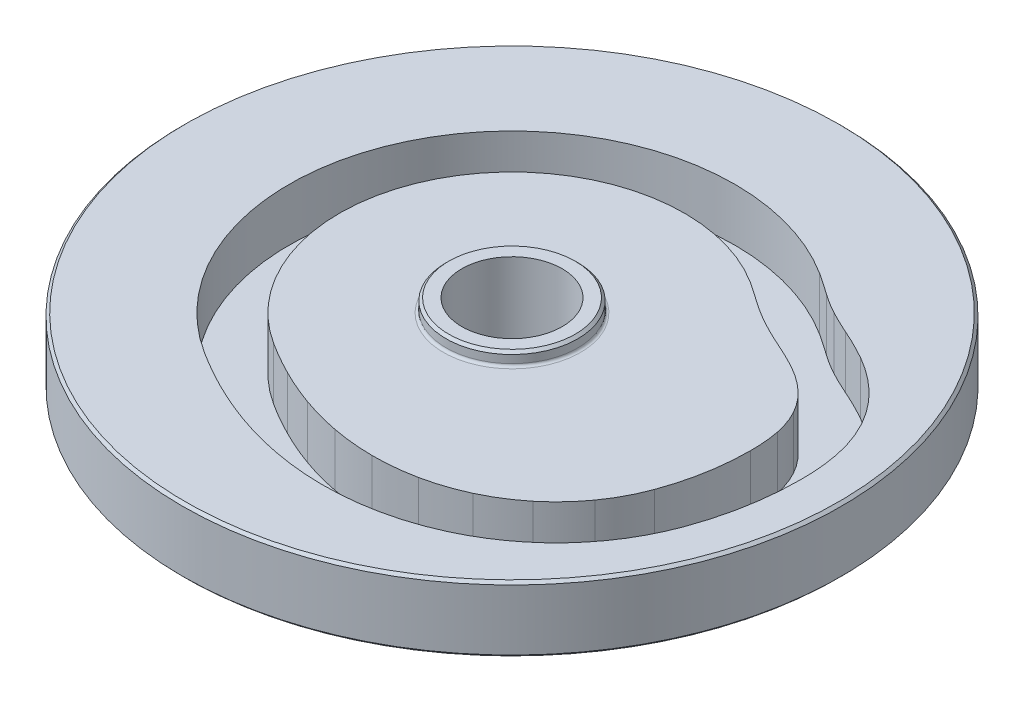
from build123d import *

# Parameters (mm, degrees)
CUT_EXTRUDE_THIN1_DEPTH      = 15
CUT_EXTRUDE_THIN1_DEPTH_BACK = 20


with BuildPart() as part:
    # Sketch1 → Base-Revolve (revolve)
    with BuildSketch(Plane.XY):
        with BuildLine():
            Line((19.05, 5), (24, 5))
            Line((24, 5), (25, 4))
            Line((25, 4), (25, 1))
            ThreePointArc((25, 1), (25.292893219, 0.292893219), (26, 0))
            Line((26, 0), (124, 0))
            Line((124, 0), (125, -1))
            Line((125, -1), (125, -24))
            Line((125, -24), (124, -25))
            Line((124, -25), (26, -25))
            ThreePointArc((26, -25), (25.292893219, -25.292893219), (25, -26))
            Line((25, -26), (25, -29))
            Line((25, -29), (24, -30))
            Line((24, -30), (19.05, -30))
            Line((19.05, -30), (19.05, 5))
        make_face()
    revolve(axis=Axis((0, -30350, 0), (0, 1, 0)))

    # Sketch2 → Cut-Extrude-Thin1 (cut, two sides)
    with BuildSketch(Plane(origin=(0, 0, 0), x_dir=(1, 0, 0), z_dir=(0, 1, 0))) as cut_extrude_thin1_sk:
        with BuildLine():
            ThreePointArc((109.524986247, -0.054887133), (109.229921991, 7.423375501), (108.184717895, 14.834112532))
            ThreePointArc((108.184717895, 14.834112532), (106.043659804, 22.548927161), (102.756924095, 29.84960267))
            ThreePointArc((102.756924095, 29.84960267), (98.332860497, 36.567183371), (92.916011248, 42.513272287))
            ThreePointArc((92.916011248, 42.513272287), (87.141221214, 47.295885443), (80.843977188, 51.366058191))
            ThreePointArc((80.843977188, 51.366058191), (75.279655517, 54.316272842), (69.579158541, 56.993916655))
            ThreePointArc((69.579158541, 56.993916655), (65.230785476, 58.999236045), (60.953055197, 61.151137028))
            ThreePointArc((60.953055197, 61.151137028), (57.290135984, 63.276226982), (53.749285638, 65.599019115))
            ThreePointArc((53.749285638, 65.599019115), (49.601954473, 68.481518372), (45.406369026, 71.293318599))
            ThreePointArc((45.406369026, 71.293318599), (-71.312570217, 45.376127579), (-45.345877971, -71.331809006))
            ThreePointArc((-45.345877971, -71.331809006), (-38.593898018, -75.405527827), (-31.649923168, -79.142589722))
            ThreePointArc((-31.649923168, -79.142589722), (-24.034421899, -82.711545409), (-16.211151125, -85.798572893))
            ThreePointArc((-16.211151125, -85.798572893), (-7.620932162, -88.510877367), (1.153325471, -90.550696085))
            ThreePointArc((1.153325471, -90.550696085), (10.620649637, -91.921398106), (20.173660561, -92.420430343))
            ThreePointArc((20.173660561, -92.420430343), (30.195991067, -91.960061817), (40.115734041, -90.457481608))
            ThreePointArc((40.115734041, -90.457481608), (50.164053761, -87.778443627), (59.835395829, -83.955994636))
            ThreePointArc((59.835395829, -83.955994636), (69.217053614, -78.865285844), (77.888616734, -72.641556104))
            ThreePointArc((77.888616734, -72.641556104), (85.826699629, -65.22323814), (92.717665183, -56.823286045))
            ThreePointArc((92.717665183, -56.823286045), (98.476591418, -47.488521124), (102.919592608, -37.460420212))
            ThreePointArc((102.919592608, -37.460420212), (107.856238797, -19.046190631), (109.524986247, -0.054887133))
        make_face()
        with BuildLine():
            ThreePointArc((90.474982456, 0.056342792), (90.262741838, 5.647173284), (89.486847533, 11.187969228))
            ThreePointArc((89.486847533, 11.187969228), (88.12991005, 16.068178084), (86.054133631, 20.688661832))
            ThreePointArc((86.054133631, 20.688661832), (83.284958022, 24.885433828), (79.899946609, 28.603353472))
            ThreePointArc((79.899946609, 28.603353472), (75.875178075, 31.93428485), (71.488414915, 34.771567807))
            ThreePointArc((71.488414915, 34.771567807), (66.751022738, 37.282035549), (61.898062734, 39.56109503))
            ThreePointArc((61.898062734, 39.56109503), (56.897401317, 41.868517981), (51.979131099, 44.346709525))
            ThreePointArc((51.979131099, 44.346709525), (47.310945971, 47.049113929), (42.801511531, 50.008834013))
            ThreePointArc((42.801511531, 50.008834013), (38.952515201, 52.685804726), (35.059073926, 55.297712072))
            ThreePointArc((35.059073926, 55.297712072), (-55.279422123, 35.087905534), (-35.1167276, -55.261117141))
            ThreePointArc((-35.1167276, -55.261117141), (-29.160317457, -58.855298852), (-23.034341253, -62.152173057))
            ThreePointArc((-23.034341253, -62.152173057), (-16.494338073, -65.217270915), (-9.775872963, -67.868439157))
            ThreePointArc((-9.775872963, -67.868439157), (-2.592647115, -70.136469906), (4.744453336, -71.842240708))
            ThreePointArc((4.744453336, -71.842240708), (12.484550044, -72.962801762), (20.294689574, -73.370814789))
            ThreePointArc((20.294689574, -73.370814789), (28.32982468, -73.001688389), (36.282721862, -71.797081864))
            ThreePointArc((36.282721862, -71.797081864), (44.198795786, -69.686506265), (51.817937068, -66.675286938))
            ThreePointArc((51.817937068, -66.675286938), (59.100153222, -62.723698973), (65.831324035, -57.892854425))
            ThreePointArc((65.831324035, -57.892854425), (71.928664779, -52.194534162), (77.221947559, -45.742435637))
            ThreePointArc((77.221947559, -45.742435637), (81.623193338, -38.607897611), (85.018936267, -30.943595477))
            ThreePointArc((85.018936267, -30.943595477), (89.105431486, -15.682719937), (90.474982456, 0.056342792))
        make_face(mode=Mode.SUBTRACT)
    extrude(amount=CUT_EXTRUDE_THIN1_DEPTH, mode=Mode.SUBTRACT)
    extrude(cut_extrude_thin1_sk.sketch, amount=-CUT_EXTRUDE_THIN1_DEPTH_BACK, mode=Mode.SUBTRACT)


solid = part.part
